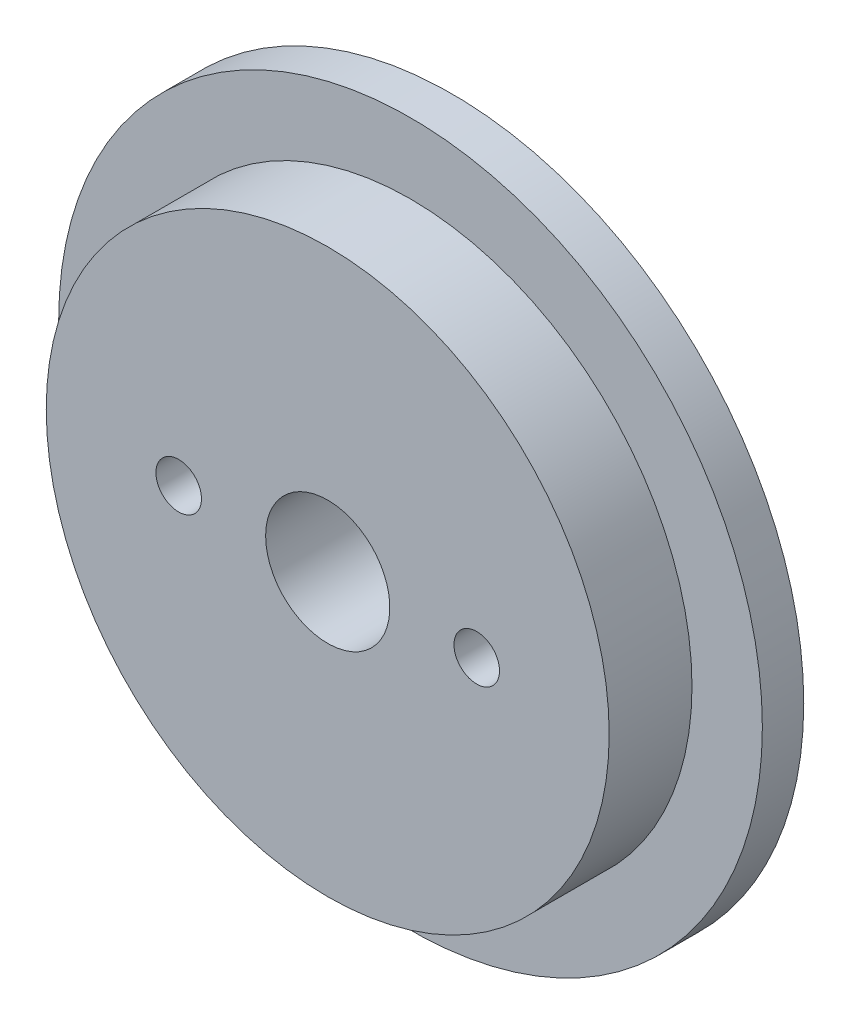
from build123d import *

# Parameters (mm, degrees)
SKIZZE1_R                        = 34
AUFSATZ_LINEAR_AUSTRAGEN1_DEPTH  = 10
SKIZZE3_R                        = 42.5
AUFSATZ_LINEAR_AUSTRAGEN2_DEPTH  = 5
F_15_0_15_DURCHMESSER_BOHRUNG1_D = 15
F_5_5_5_5_DURCHMESSER_BOHRUNG1_D = 5.5


with BuildPart() as part:
    # Skizze1 → Aufsatz-Linear austragen1 (new body)
    with BuildSketch(Plane.XY):
        Circle(SKIZZE1_R)
    extrude(amount=AUFSATZ_LINEAR_AUSTRAGEN1_DEPTH)

    # Skizze3 → Aufsatz-Linear austragen2 (add)
    with BuildSketch(Plane(origin=(0, 0, 0), x_dir=(-1, 0, 0), z_dir=(0, 0, -1))):
        Circle(SKIZZE3_R)
    extrude(amount=AUFSATZ_LINEAR_AUSTRAGEN2_DEPTH)

    # Ø15.0 (15) Durchmesser Bohrung1 (through all)
    with Locations(Plane(origin=(0, 0, -5), x_dir=(-1, 0, 0), z_dir=(0, 0, -1))):
        with Locations((0, 0)):
            Hole(F_15_0_15_DURCHMESSER_BOHRUNG1_D / 2)

    # Ø5.5 (5.5) Durchmesser Bohrung1 (through all)
    with Locations(Plane(origin=(0, 0, -5), x_dir=(-1, 0, 0), z_dir=(0, 0, -1))):
        with Locations((18, 0), (-18, 0)):
            Hole(F_5_5_5_5_DURCHMESSER_BOHRUNG1_D / 2)


solid = part.part
